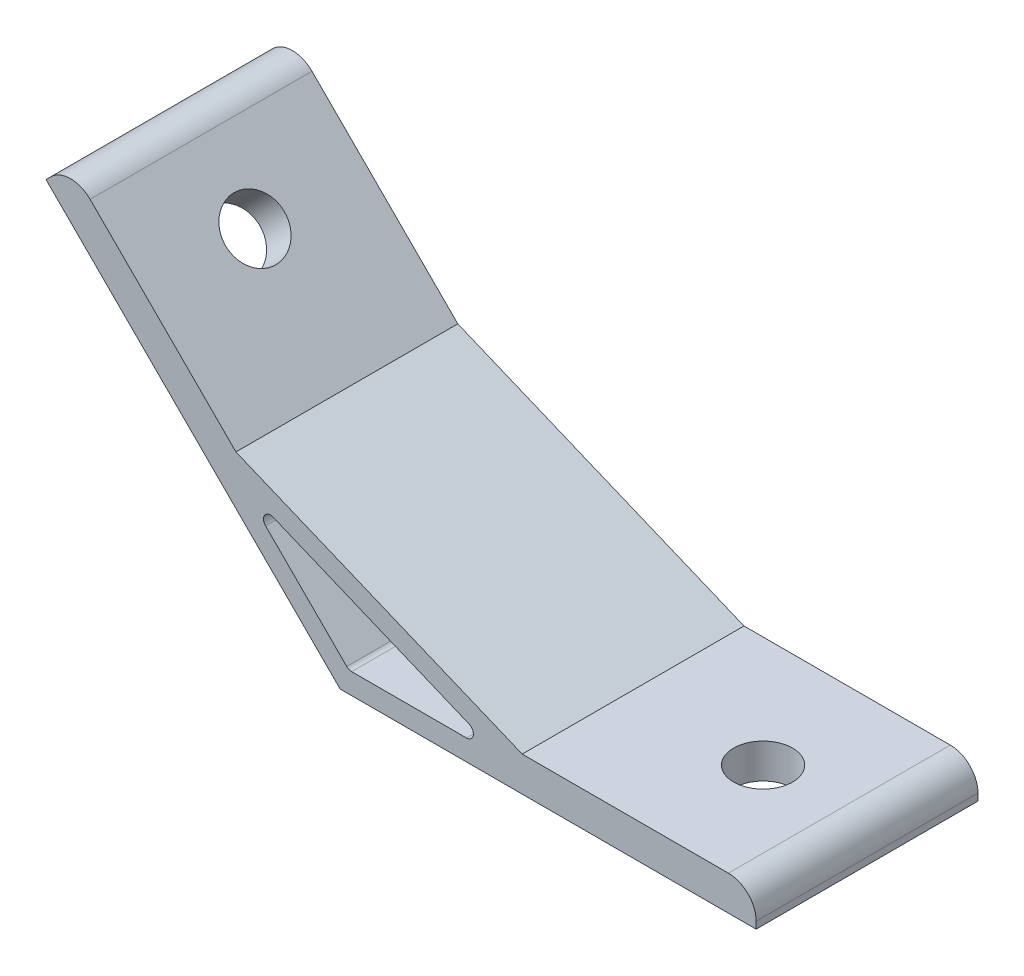
from build123d import *

# Parameters (mm, degrees)
EXTRUDE_1_DEPTH     = 16
SKETCH_2_R          = 4.25
CUT_EXTRUDE_1_DEPTH = 5
SKETCH_3_R          = 4.25
CUT_EXTRUDE_2_DEPTH = 5
FILLET_1_R          = 4
FILLET_2_R          = 1


with BuildPart() as part:
    # Эскиз1 → Бобышка-Вытянуть1 (new body, symmetric)
    with BuildSketch(Plane.XY):
        Polygon((0, 0), (-42.426406871, 42.426406871), (-38.890872965, 45.961940777), (-15.028558569, 22.099626381), (26.253591352, 5), (60, 5), (60, 0), align=None)
        Polygon((-14.313708499, 18.556349186), (23.242640687, 3), (1.242640687, 3), align=None, mode=Mode.SUBTRACT)
    extrude(amount=EXTRUDE_1_DEPTH, both=True)

    # Эскиз2 → Вырез-Вытянуть1 (cut)
    with BuildSketch(Plane(origin=(0, 0, 0), x_dir=(0, 0, 1), z_dir=(-0.707106781, -0.707106781, 0))):
        with Locations(Location((0, 45, 0), (0, 0, 270))):  # turned: the seam where the file's is
            Circle(SKETCH_2_R)
    extrude(amount=-CUT_EXTRUDE_1_DEPTH, mode=Mode.SUBTRACT)

    # Эскиз3 → Вырез-Вытянуть2 (cut)
    with BuildSketch(Plane.XZ):
        with Locations(Location((45, 0, 0), (0, 0, 270))):  # turned: the seam where the file's is
            Circle(SKETCH_3_R)
    extrude(amount=-CUT_EXTRUDE_2_DEPTH, mode=Mode.SUBTRACT)

    # Скругление1
    fillet_1_edges = [part.edges().sort_by_distance(p)[0] for p in [
        (-38.890872965, 45.961940777, 0),
        (60, 5, 0),
    ]]
    fillet(fillet_1_edges, radius=FILLET_1_R)

    # Скругление2
    fillet_2_edges = [part.edges().sort_by_distance(p)[0] for p in [
        (-14.313708499, 18.556349186, 0),
        (1.242640687, 3, 0),
        (23.242640687, 3, 0),
    ]]
    fillet(fillet_2_edges, radius=FILLET_2_R)


solid = part.part
